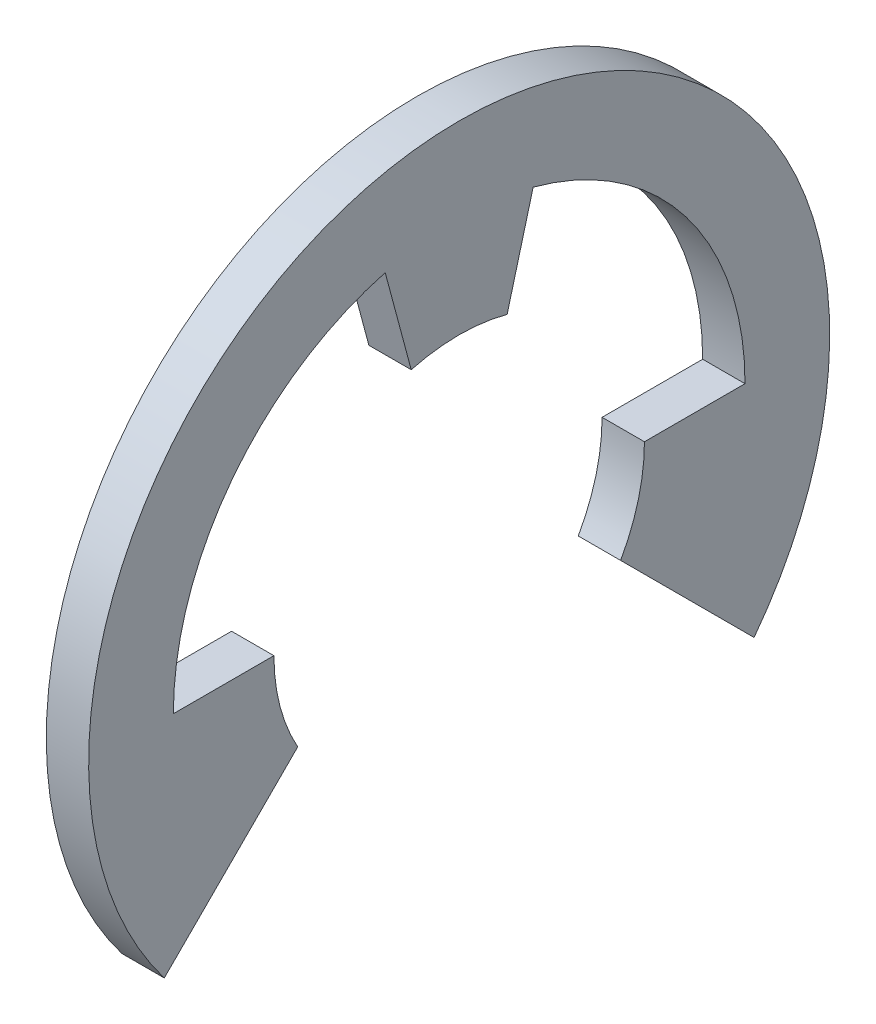
from build123d import *

# Parameters (mm, degrees)
BOSS_EXTRUDE1_DEPTH = 0.8


with BuildPart() as part:
    # Sketch1 → Boss-Extrude1 (new body)
    with BuildSketch(Plane(origin=(0, 0, 0), x_dir=(0, 0, -1), z_dir=(1, 0, 0))):
        with BuildLine():
            Line((-3.5, 0), (-5.4, 0))
            ThreePointArc((-5.4, 0), (-4.284108038, 3.287311717), (-1.397622844, 5.215999462))
            Line((-1.397622844, 5.215999462), (-0.905866658, 3.380740392))
            ThreePointArc((-0.905866658, 3.380740392), (0, 3.5), (0.905866658, 3.380740392))
            Line((0.905866658, 3.380740392), (1.397622844, 5.215999462))
            ThreePointArc((1.397622844, 5.215999462), (4.284108038, 3.287311717), (5.4, 0))
            Line((5.4, 0), (3.5, 0))
            ThreePointArc((3.5, 0), (3.385631403, -0.887411967), (3.05, -1.716828471))
            Line((3.05, -1.716828471), (5.571243084, -4.238071555))
            ThreePointArc((5.571243084, -4.238071555), (0, 7), (-5.571243084, -4.238071555))
            Line((-5.571243084, -4.238071555), (-3.05, -1.716828471))
            ThreePointArc((-3.05, -1.716828471), (-3.385631403, -0.887411967), (-3.5, 0))
        make_face()
    extrude(amount=BOSS_EXTRUDE1_DEPTH)


solid = part.part
